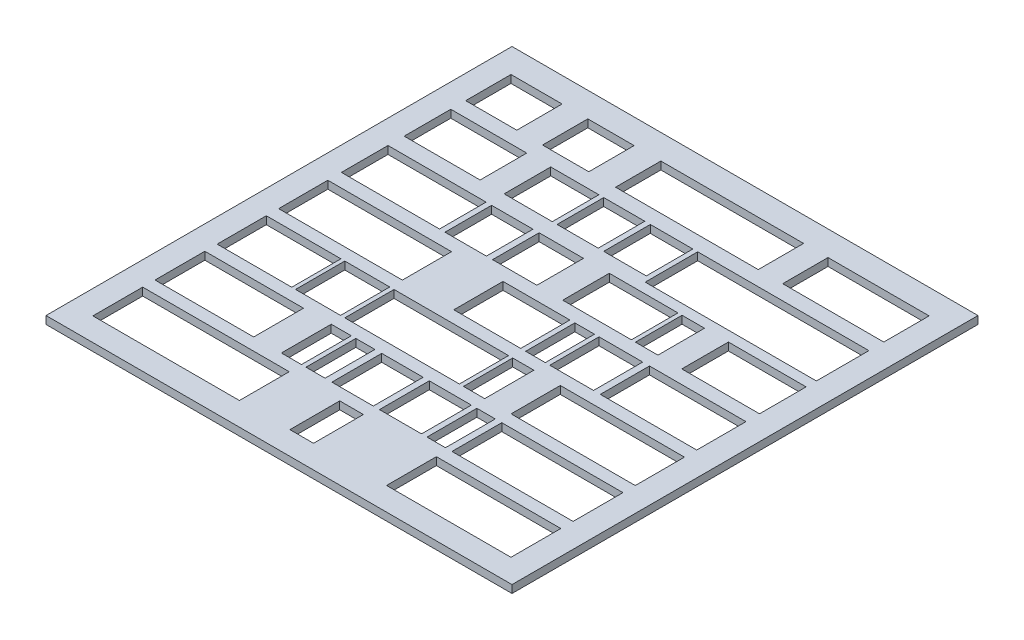
from build123d import *

# Parameters (mm, degrees)
SKETCH1_W           = 190.5
SKETCH1_H           = 190.5
BOSS_EXTRUDE1_DEPTH = 3.175
SKETCH4_W           = 20.902
SKETCH4_H           = 18.5208
SKETCH4_W_2         = 18.9176
SKETCH4_W_3         = 58.3406
SKETCH4_W_4         = 41.3228
SKETCH4_H_2         = 18.521
SKETCH4_W_5         = 31.0406
SKETCH4_H_3         = 19.0502
SKETCH4_W_6         = 19.6834
SKETCH4_W_7         = 16.801
SKETCH4_W_8         = 17.3964
SKETCH4_W_9         = 69.9784
SKETCH4_H_4         = 21.4674
SKETCH4_W_10        = 9.1858
SKETCH4_H_5         = 19.05
SKETCH4_W_11        = 40.0886
SKETCH4_W_12        = 16.9334
SKETCH4_W_13        = 18.124
SKETCH4_W_14        = 28.07
SKETCH4_W_15        = 31.7698
SKETCH4_W_16        = 50.5814
SKETCH4_H_6         = 20.1082
SKETCH4_W_17        = 27.3424
SKETCH4_W_18        = 8.028
SKETCH4_W_19        = 39.4186
SKETCH4_W_20        = 17.8594
SKETCH4_W_21        = 30.497
SKETCH4_H_7         = 20.1084
SKETCH4_W_22        = 18.3882
SKETCH4_W_23        = 46.8316
SKETCH4_W_24        = 8.6652
SKETCH4_W_25        = 50.754
SKETCH4_W_26        = 40.3286
SKETCH4_H_8         = 20.3728
SKETCH4_W_27        = 8.202
SKETCH4_W_28        = 7.8052
SKETCH4_W_29        = 17.198
SKETCH4_W_30        = 7.5406
SKETCH4_W_31        = 49.5384
SKETCH4_W_32        = 59.9076
SKETCH4_W_33        = 9.6572
SKETCH4_W_34        = 50.861
CUT_EXTRUDE2_DEPTH  = 4.175


with BuildPart() as part:
    # Sketch1 → Boss-Extrude1 (new body)
    with BuildSketch(Plane(origin=(0, 0, 0), x_dir=(1, 0, 0), z_dir=(0, 1, 0))):
        Rectangle(SKETCH1_W, SKETCH1_H)
    extrude(amount=BOSS_EXTRUDE1_DEPTH)

    # Sketch4 → Cut-Extrude2 (cut, through all)
    with BuildSketch(Plane(origin=(0, 3.175, 0), x_dir=(1, 0, 0), z_dir=(0, 1, 0))):
        with Locations((-75.0878, 75.8609)):
            Rectangle(SKETCH4_W, SKETCH4_H)
        with Locations((-44.6608, 75.8609)):
            Rectangle(SKETCH4_W_2, SKETCH4_H)
        with Locations((4.9001, 75.8609)):
            Rectangle(SKETCH4_W_3, SKETCH4_H)
        with Locations((64.7206, 75.8608)):
            Rectangle(SKETCH4_W_4, SKETCH4_H_2)
        with Locations((-70.0185, 50.9899)):
            Rectangle(SKETCH4_W_5, SKETCH4_H_3)
        with Locations((-34.8388, 50.9899)):
            Rectangle(SKETCH4_W_6, SKETCH4_H_3)
        with Locations((-14.6268, 50.9899)):
            Rectangle(SKETCH4_W_7, SKETCH4_H_3)
        with Locations((4.721, 50.9899)):
            Rectangle(SKETCH4_W_8, SKETCH4_H_3)
        with Locations((50.3928, 49.7813)):
            Rectangle(SKETCH4_W_9, SKETCH4_H_4)
        with Locations((39.2539, 25.3254)):
            Rectangle(SKETCH4_W_10, SKETCH4_H_5)
        with Locations((-65.4945, 25.3254)):
            Rectangle(SKETCH4_W_11, SKETCH4_H_5)
        with Locations((-34.7345, 25.3254)):
            Rectangle(SKETCH4_W_12, SKETCH4_H_5)
        with Locations((-14.6923, 25.3254)):
            Rectangle(SKETCH4_W_13, SKETCH4_H_5)
        with Locations((18.9639, 25.3254)):
            Rectangle(SKETCH4_W_14, SKETCH4_H_5)
        with Locations((69.4971, 25.3254)):
            Rectangle(SKETCH4_W_15, SKETCH4_H_5)
        with Locations((-60.2481, 0.19)):
            Rectangle(SKETCH4_W_16, SKETCH4_H_6)
        with Locations((-0.2517, 0.19)):
            Rectangle(SKETCH4_W_17, SKETCH4_H_6)
        with Locations((19.4598, 0.19)):
            Rectangle(SKETCH4_W_18, SKETCH4_H_6)
        with Locations((65.6727, 0.19)):
            Rectangle(SKETCH4_W_19, SKETCH4_H_6)
        with Locations((34.2556, 0.19)):
            Rectangle(SKETCH4_W_20, SKETCH4_H_6)
        with Locations((-70.2903, -24.9455)):
            Rectangle(SKETCH4_W_21, SKETCH4_H_7)
        with Locations((-44.2841, -24.9455)):
            Rectangle(SKETCH4_W_22, SKETCH4_H_7)
        with Locations((-9.93, -24.9455)):
            Rectangle(SKETCH4_W_23, SKETCH4_H_7)
        with Locations((19.5051, -24.9455)):
            Rectangle(SKETCH4_W_24, SKETCH4_H_7)
        with Locations((60.0051, -24.9455)):
            Rectangle(SKETCH4_W_25, SKETCH4_H_7)
        with Locations((-65.3745, -50.2132)):
            Rectangle(SKETCH4_W_26, SKETCH4_H_8)
        with Locations((-29.7731, -50.2132)):
            Rectangle(SKETCH4_W_27, SKETCH4_H_8)
        with Locations((-4.7699, -50.2132)):
            Rectangle(SKETCH4_W_12, SKETCH4_H_8)
        with Locations((-19.9173, -50.2132)):
            Rectangle(SKETCH4_W_28, SKETCH4_H_8)
        with Locations((14.8093, -50.2132)):
            Rectangle(SKETCH4_W_29, SKETCH4_H_8)
        with Locations((29.4275, -50.2132)):
            Rectangle(SKETCH4_W_30, SKETCH4_H_8)
        with Locations((60.6129, -50.2132)):
            Rectangle(SKETCH4_W_31, SKETCH4_H_8)
        with Locations((-55.585, -75.6132)):
            Rectangle(SKETCH4_W_32, SKETCH4_H_8)
        with Locations((-0.1649, -75.6132)):
            Rectangle(SKETCH4_W_33, SKETCH4_H_8)
        with Locations((59.9515, -75.6132)):
            Rectangle(SKETCH4_W_34, SKETCH4_H_8)
    extrude(amount=-CUT_EXTRUDE2_DEPTH, mode=Mode.SUBTRACT)


solid = part.part
